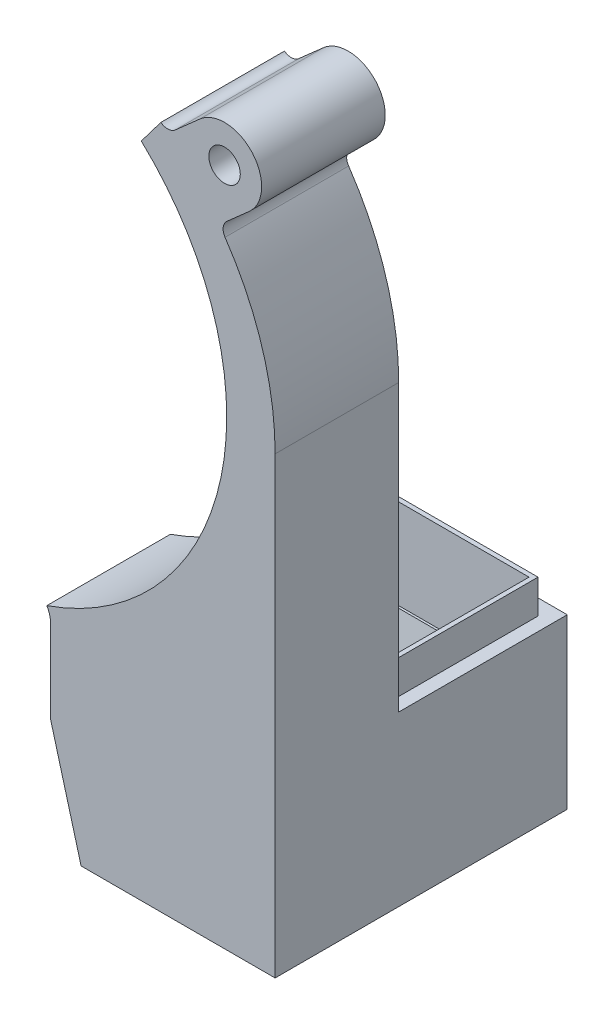
from build123d import *

# Parameters (mm, degrees)
SKETCH1_R               = 1.4
BOSS_EXTRUDE1_DEPTH     = 11
SKETCH2_W               = 18.000000053
SKETCH2_H               = 12.9
SKETCH2_W_2             = 16.800000053
SKETCH2_H_2             = 11.7
BOSS_EXTRUDE2_DEPTH     = 3
SKETCH2_3_W             = 20
SKETCH2_3_H             = 11
SKETCH2_3_H_2           = 15
SKETCH2_3_W_2           = 18.000000053
SKETCH2_3_H_3           = 12.9
SKETCH2_3_W_3           = 16.800000053
SKETCH2_3_H_4           = 11.7
BOSS_EXTRUDE3_DEPTH     = 5
BOSS_EXTRUDE4_DEPTH     = 2
BOSS_EXTRUDE6_START     = -2
BOSS_EXTRUDE6_DEPTH     = 22
SKETCH4_3_W             = 2
SKETCH4_3_H             = 40
BOSS_EXTRUDE6_2_DEPTH   = 22
BOSS_EXTRUDE7_START     = -24
SKETCH4_4_W             = 2
SKETCH4_4_H             = 40
BOSS_EXTRUDE7_DEPTH     = 2
BOSS_EXTRUDE8_REACH     = 20.326
SKETCH2_5_W             = 18.000000053
SKETCH2_5_H             = 12.9
SKETCH2_5_W_2           = 17.600000053
SKETCH2_5_H_2           = 12.5
CUT_EXTRUDE_THIN6_DEPTH = 10
SKETCH11_W              = 50.134644107
SKETCH11_H              = 30
CUT_EXTRUDE6_DEPTH      = 27


with BuildPart() as part:
    # Sketch1 → Boss-Extrude1 (new body)
    with BuildSketch(Plane.XY):
        with BuildLine():
            Line((23.20688118, 15.778885673), (25.185252728, 17.527214018))
            ThreePointArc((25.185252728, 17.527214018), (25.472785982, 22.185252728), (20.814747272, 22.472785982))
            Line((20.814747272, 22.472785982), (18.598905377, 20.514600122))
            ThreePointArc((18.598905377, 20.514600122), (17.974550182, 20.264645495), (17.333078903, 20.466663618))
            Line((17.333078903, 20.466663618), (15.586200014, 18.159406728))
            ThreePointArc((15.586200014, 18.159406728), (22.681435087, -4.226534244), (7.174093823, -21.861586862))
            ThreePointArc((7.174093823, -21.861586862), (7.416792587, -22.384967182), (7.5, -22.955849111))
            Line((7.5, -22.955849111), (7.5, -25.4))
            Line((7.5, -25.4), (27.5, -25.4))
            Line((27.5, -25.4), (27.5, 0))
            ThreePointArc((27.5, 0), (26.362874376, 7.569397218), (23.04284729, 14.466226133))
            ThreePointArc((23.04284729, 14.466226133), (22.876796583, 15.153555184), (23.20688118, 15.778885673))
        make_face()
        with Locations((23, 20)):
            Circle(SKETCH1_R, mode=Mode.SUBTRACT)
    extrude(amount=BOSS_EXTRUDE1_DEPTH)



with BuildPart() as body_2:
    # Sketch2 → Boss-Extrude2 (new body)
    with BuildSketch(Plane.XZ.offset(25.4)):
        with Locations((17.500000027, -7.35)):
            Rectangle(SKETCH2_W, SKETCH2_H)
        with Locations((17.500000027, -7.35)):
            Rectangle(SKETCH2_W_2, SKETCH2_H_2, mode=Mode.SUBTRACT)
    extrude(amount=-BOSS_EXTRUDE2_DEPTH)


with BuildPart() as part_1:
    add(part.part)

    add(body_2.part)  # Boss-Extrude3 merges body 2
    # Sketch2_3 → Boss-Extrude3 (add)
    with BuildSketch(Plane.XZ.offset(25.4)):
        with Locations((17.5, 5.5)):
            Rectangle(SKETCH2_3_W, SKETCH2_3_H)
        with Locations((17.5, -7.5)):
            Rectangle(SKETCH2_3_W, SKETCH2_3_H_2)
        with Locations((17.500000027, -7.35)):
            Rectangle(SKETCH2_3_W_2, SKETCH2_3_H_3, mode=Mode.SUBTRACT)
        with Locations((17.500000027, -7.35)):
            Rectangle(SKETCH2_3_W_2, SKETCH2_3_H_3)
        with Locations((17.500000027, -7.35)):
            Rectangle(SKETCH2_3_W_3, SKETCH2_3_H_4, mode=Mode.SUBTRACT)
    extrude(amount=BOSS_EXTRUDE3_DEPTH)

    # Sketch4 → Boss-Extrude4 (add)
    with BuildSketch(Plane(origin=(0, 0, -15), x_dir=(-1, 0, 0), z_dir=(0, 0, -1))):
        Polygon((-18.42672165, -70.4), (-7.5, -30.4), (-27.5, -30.4), (-27.5, -70.4), align=None)
    extrude(amount=-BOSS_EXTRUDE4_DEPTH)



with BuildPart() as body_2_2:
    # Sketch4_3 → Boss-Extrude6 (new body)
    with BuildSketch(Plane(origin=(0, 0, -15), x_dir=(-1, 0, 0), z_dir=(0, 0, -1)).offset(BOSS_EXTRUDE6_START)):
        Polygon((-18.42672165, -70.4), (-7.5, -30.4), (-9.57327835, -30.4), (-20.5, -70.4), align=None)
    extrude(amount=-BOSS_EXTRUDE6_DEPTH)


with BuildPart() as body_3:
    # Sketch4_3 → Boss-Extrude6 2 (new body)
    with BuildSketch(Plane(origin=(0, 0, -15), x_dir=(-1, 0, 0), z_dir=(0, 0, -1)).offset(BOSS_EXTRUDE6_START)):
        with Locations((-26.5, -50.4)):
            Rectangle(SKETCH4_3_W, SKETCH4_3_H)
    extrude(amount=-BOSS_EXTRUDE6_2_DEPTH)


with BuildPart() as part_2:
    add(part_1.part)

    add(body_2_2.part)  # Boss-Extrude7 merges body 2 2

    add(body_3.part)  # Boss-Extrude7 merges body 3
    # Sketch4_4 → Boss-Extrude7 (add)
    with BuildSketch(Plane(origin=(0, 0, -15), x_dir=(-1, 0, 0), z_dir=(0, 0, -1)).offset(BOSS_EXTRUDE7_START)):
        Polygon((-20.5, -70.4), (-9.57327835, -30.4), (-25.5, -30.4), (-25.5, -70.4), align=None)
        Polygon((-18.42672165, -70.4), (-7.5, -30.4), (-9.57327835, -30.4), (-20.5, -70.4), align=None)
        with Locations((-26.5, -50.4)):
            Rectangle(SKETCH4_4_W, SKETCH4_4_H)
    extrude(amount=-BOSS_EXTRUDE7_DEPTH)

    # Boss-Extrude8: up to this face of the body (flat: up to its plane)
    boss_extrude8_end = Plane(part_2.part.faces().sort_by_distance((15.036639175, -50.4, -2))[0])
    # Sketch8 → Boss-Extrude8 (add, up to the picked face)
    with BuildSketch(Plane.ZY.offset(-25.5), mode=Mode.PRIVATE) as boss_extrude8_sk1:
        Polygon((-13, -70.4), (-6, -70.4), (-13, -30.4), align=None)
    boss_extrude8_tool1 = split(extrude(boss_extrude8_sk1.sketch, amount=BOSS_EXTRUDE8_REACH, mode=Mode.PRIVATE), bisect_by=boss_extrude8_end, keep=Keep.BOTH, mode=Mode.PRIVATE)
    add(boss_extrude8_tool1.solids().sort_by_distance((25.5, -57.066667, -10.666667))[0])

    # Sketch2_5 → Cut-Extrude-Thin6 (cut)
    with BuildSketch(Plane.XZ.offset(25.4)):
        with Locations((17.500000027, -7.35)):
            Rectangle(SKETCH2_5_W, SKETCH2_5_H)
        with Locations((17.500000027, -7.35)):
            Rectangle(SKETCH2_5_W_2, SKETCH2_5_H_2, mode=Mode.SUBTRACT)
    extrude(amount=-CUT_EXTRUDE_THIN6_DEPTH, mode=Mode.SUBTRACT)

    # Sketch11 → Cut-Extrude6 (cut, through all)
    with BuildSketch(Plane(origin=(0, 0, -15), x_dir=(-1, 0, 0), z_dir=(0, 0, -1))):
        with Locations((-25.067322053, -55.4)):
            Rectangle(SKETCH11_W, SKETCH11_H)
    extrude(amount=-CUT_EXTRUDE6_DEPTH, mode=Mode.SUBTRACT)


solid = part_2.part
